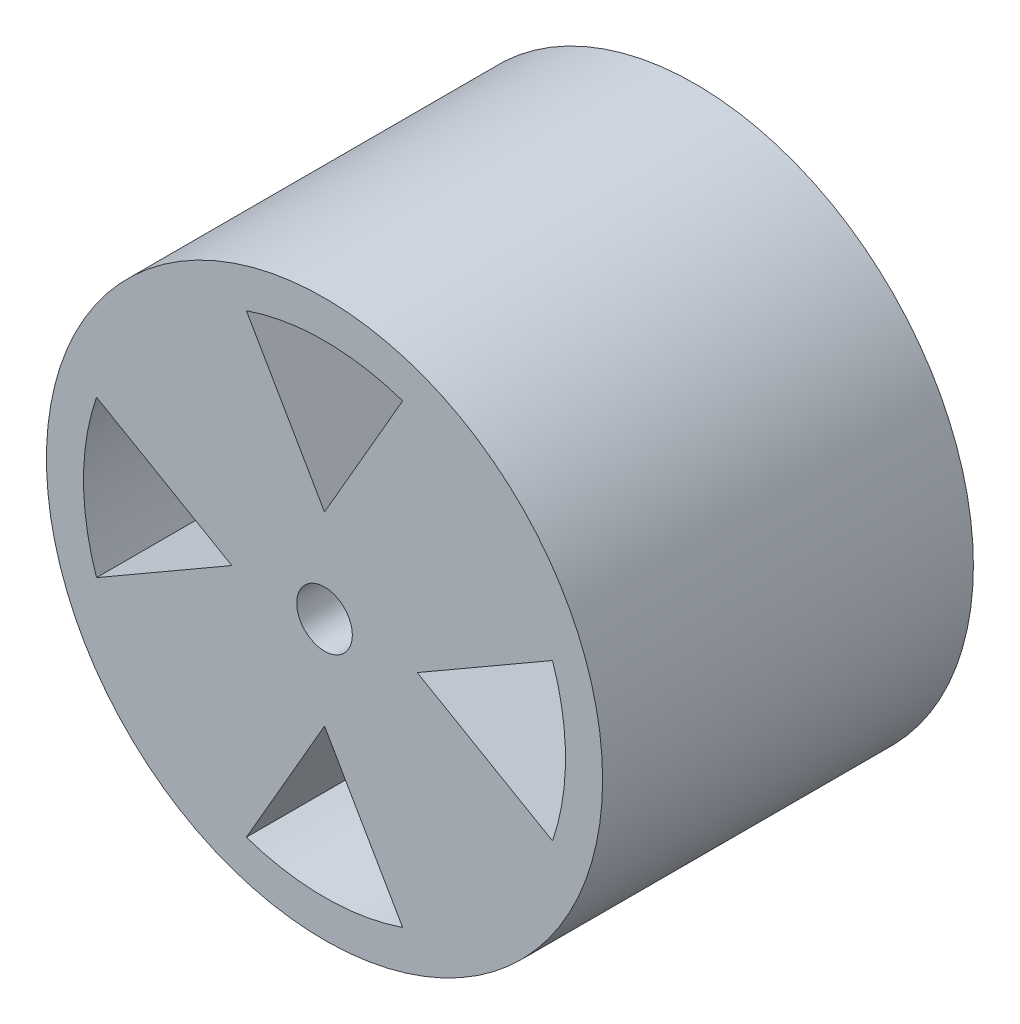
from build123d import *

# Parameters (mm, degrees)
SKETCH1_R           = 7.5
SKETCH1_R_2         = 0.75
BOSS_EXTRUDE1_DEPTH = 10
CUT_EXTRUDE1_DEPTH  = 11


with BuildPart() as part:
    # Sketch1 → Boss-Extrude1 (new body)
    with BuildSketch(Plane.XY):
        Circle(SKETCH1_R)
        Circle(SKETCH1_R_2, mode=Mode.SUBTRACT)
    extrude(amount=BOSS_EXTRUDE1_DEPTH)

    # Sketch2 → Cut-Extrude1 (cut, through all)
    with BuildSketch(Plane.XY.offset(10)):
        with BuildLine():
            Line((2.106805951, -6.149094948), (0, -2.5))
            Line((0, -2.5), (-2.106805951, -6.149094948))
            ThreePointArc((-2.106805951, -6.149094948), (0, -6.5), (2.106805951, -6.149094948))
        make_face()
        with BuildLine():
            Line((-6.149094948, -2.106805951), (-2.5, 0))
            Line((-2.5, 0), (-6.149094948, 2.106805951))
            ThreePointArc((-6.149094948, 2.106805951), (-6.5, 0), (-6.149094948, -2.106805951))
        make_face()
        with BuildLine():
            Line((6.149094948, 2.106805951), (2.5, 0))
            Line((2.5, 0), (6.149094948, -2.106805951))
            ThreePointArc((6.149094948, -2.106805951), (6.5, 0), (6.149094948, 2.106805951))
        make_face()
        with BuildLine():
            Line((-2.106805951, 6.149094948), (0, 2.5))
            Line((0, 2.5), (2.106805951, 6.149094948))
            ThreePointArc((2.106805951, 6.149094948), (0, 6.5), (-2.106805951, 6.149094948))
        make_face()
    extrude(amount=-CUT_EXTRUDE1_DEPTH, mode=Mode.SUBTRACT)


solid = part.part
